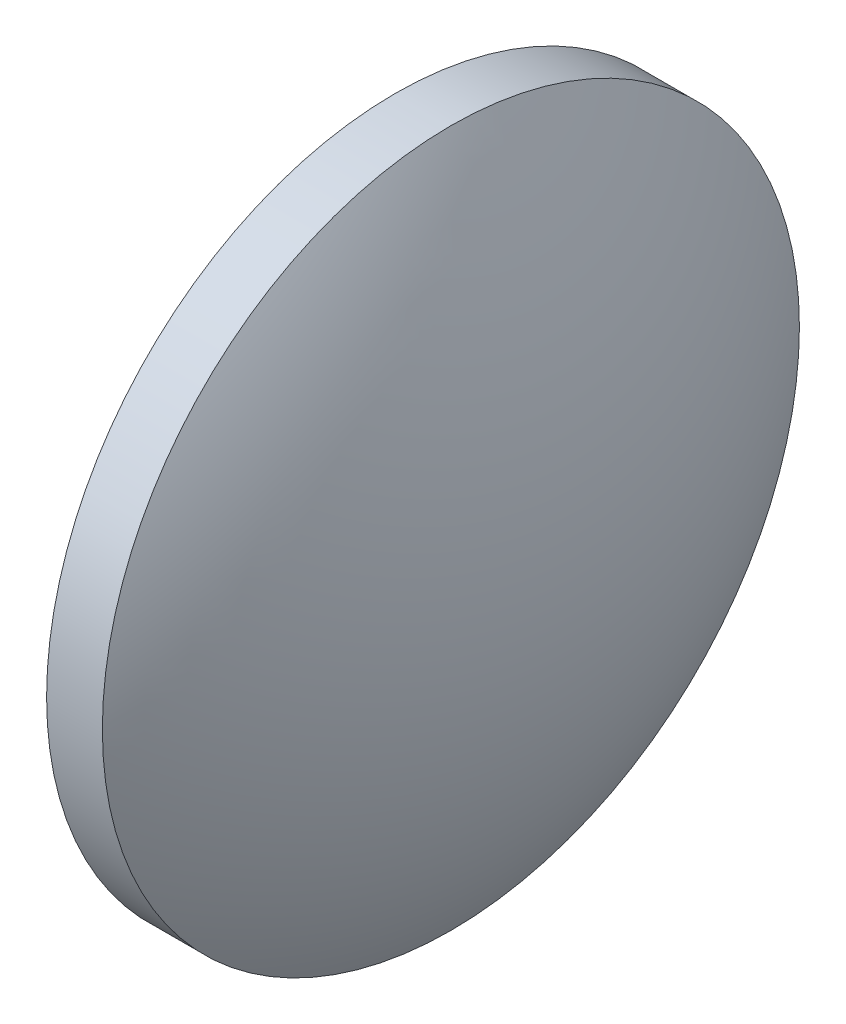
from build123d import *

# Parameters (mm, degrees)
SKETCH_1_ONE_SIDE_W = 2
SKETCH_1_ONE_SIDE_H = 12.5


with BuildPart() as part:
    # 草图1 one side → 旋转1 (revolve)
    with BuildSketch(Plane.XY):
        with Locations((85.096647416, 54.100504944)):
            Rectangle(SKETCH_1_ONE_SIDE_W, SKETCH_1_ONE_SIDE_H)
        with BuildLine():
            Line((80.616647416, 47.850504944), (84.096647416, 47.850504944))
            Line((84.096647416, 47.850504944), (84.096647416, 60.350504944))
            ThreePointArc((84.096647416, 60.350504944), (81.502881826, 54.338193284), (80.616647416, 47.850504944))
        make_face()
        with BuildLine():
            Line((86.096647416, 47.850504944), (89.576647416, 47.850504944))
            ThreePointArc((89.576647416, 47.850504944), (88.690413006, 54.338193284), (86.096647416, 60.350504944))
            Line((86.096647416, 60.350504944), (86.096647416, 47.850504944))
        make_face()
    revolve(axis=Axis((76.626212861, 47.850504944, 0), (1, 0, 0)))


solid = part.part
